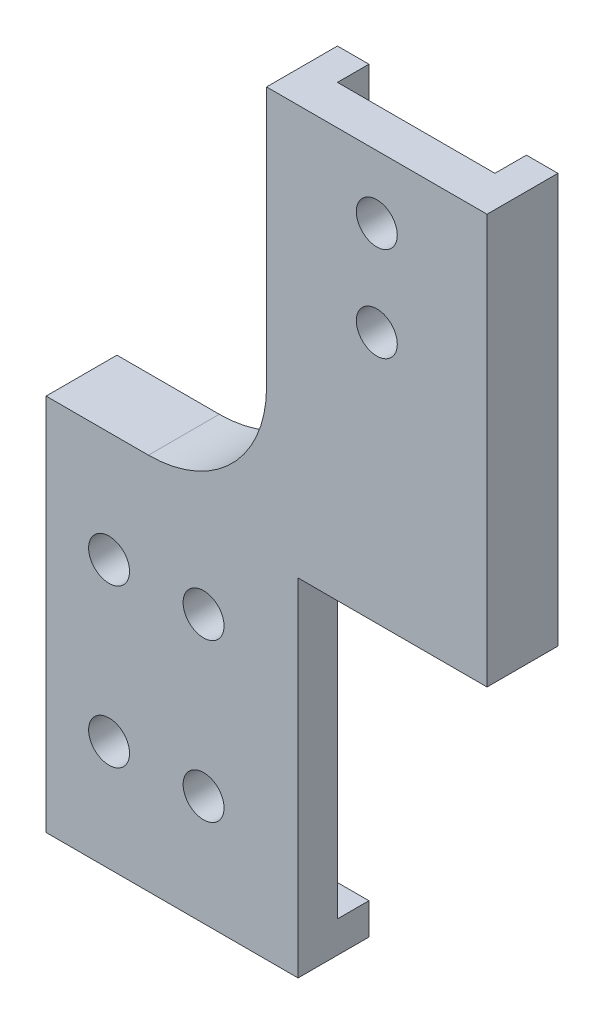
from build123d import *

# Parameters (mm, degrees)
SKETCH1_R           = 2.6
BOSS_EXTRUDE1_DEPTH = 5
SKETCH3_W           = 32
SKETCH3_H           = 4
SKETCH3_W_2         = 4
SKETCH3_H_2         = 52
BOSS_EXTRUDE3_DEPTH = 4
FILLET1_R           = 15


with BuildPart() as part:
    # Sketch1 → Boss-Extrude1 (new body)
    with BuildSketch(Plane.XY):
        Polygon((-11.163233534, 11.489286615), (-39.163233534, 11.489286615), (-39.163233534, -36.510713385), (-7.163233534, -36.510713385), (-7.163233534, 7.489286615), (16.836766466, 7.489286615), (16.836766466, 59.489286615), (-11.163233534, 59.489286615), align=None)
        with Locations((-31.163233534, -22.510713385)):
            Circle(SKETCH1_R, mode=Mode.SUBTRACT)
        with Locations((-19.163233534, -22.510713385)):
            Circle(SKETCH1_R, mode=Mode.SUBTRACT)
        with Locations((-31.163233534, -2.510713385)):
            Circle(SKETCH1_R, mode=Mode.SUBTRACT)
        with Locations((-19.163233534, -2.510713385)):
            Circle(SKETCH1_R, mode=Mode.SUBTRACT)
        with Locations((2.836766466, 39.489286615)):
            Circle(SKETCH1_R, mode=Mode.SUBTRACT)
        with Locations((2.836766466, 51.489286615)):
            Circle(SKETCH1_R, mode=Mode.SUBTRACT)
    extrude(amount=BOSS_EXTRUDE1_DEPTH)

    # Sketch3 → Boss-Extrude3 (add)
    with BuildSketch(Plane(origin=(0, 0, 0), x_dir=(-1, 0, 0), z_dir=(0, 0, -1))):
        with Locations((23.163233534, -34.510713385)):
            Rectangle(SKETCH3_W, SKETCH3_H)
        Polygon((39.163233534, 11.489286615), (11.163233534, 11.489286615), (11.163233534, 59.489286615), (7.163233534, 59.489286615), (7.163233534, 7.489286615), (39.163233534, 7.489286615), align=None)
        with Locations((-14.836766466, 33.489286615)):
            Rectangle(SKETCH3_W_2, SKETCH3_H_2)
    extrude(amount=BOSS_EXTRUDE3_DEPTH)

    # Fillet1
    fillet1_edges = [part.edges().sort_by_distance(p)[0] for p in [
        (-11.163233534, 11.489286615, 0.5),
    ]]
    fillet(fillet1_edges, radius=FILLET1_R)


solid = part.part
